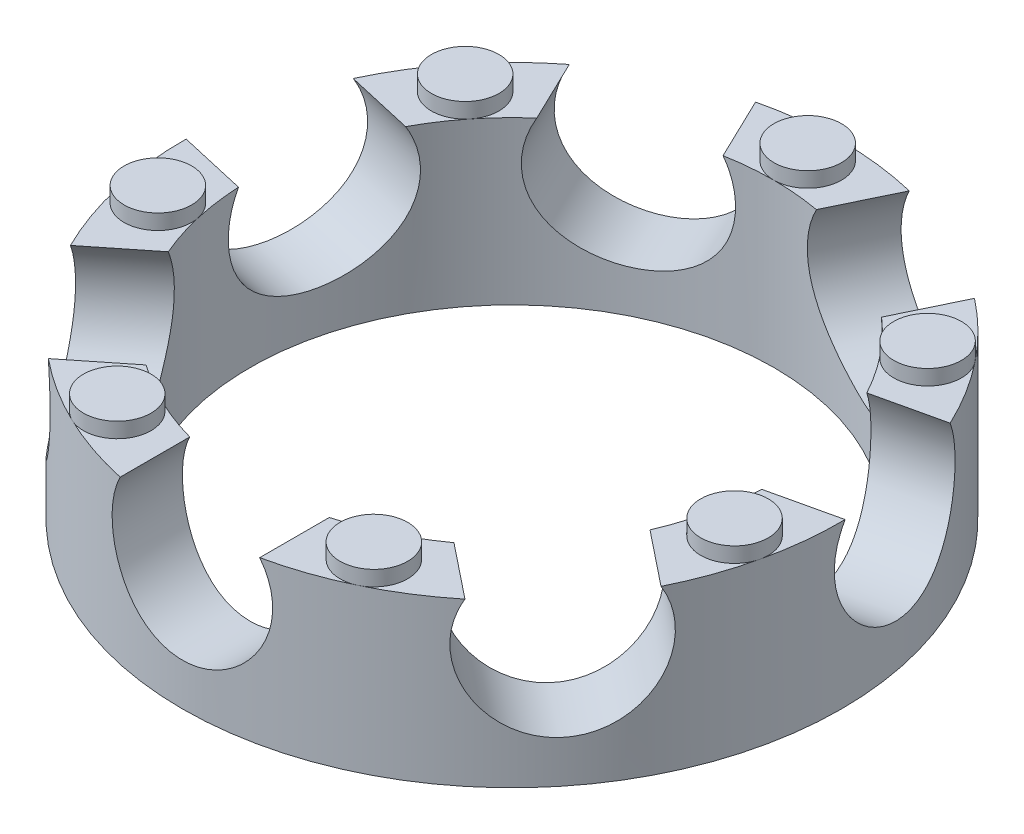
from build123d import *

# Parameters (mm, degrees)
SKETCH1_R           = 4.953
BOSS_EXTRUDE1_DEPTH = 2.4384
SKETCH2_R           = 3.937
CUT_EXTRUDE1_DEPTH  = 2.4384
SKETCH3_R           = 0.508
BOSS_EXTRUDE2_DEPTH = 2.667
CUT_EXTRUDE2_START  = 3.747576
SKETCH4_R           = 1.2065
CUT_EXTRUDE2_DEPTH  = 1.205424
CIRPATTERN1_COUNT   = 7


with BuildPart() as part:
    # Sketch1 → Boss-Extrude1 (new body)
    with BuildSketch(Plane(origin=(0, 0, 0), x_dir=(1, 0, 0), z_dir=(0, 1, 0))):
        Circle(SKETCH1_R)
    extrude(amount=BOSS_EXTRUDE1_DEPTH)

    # Sketch2 → Cut-Extrude1 (cut)
    with BuildSketch(Plane(origin=(0, 2.4384, 0), x_dir=(1, 0, 0), z_dir=(0, 1, 0))):
        Circle(SKETCH2_R)
    extrude(amount=-CUT_EXTRUDE1_DEPTH, mode=Mode.SUBTRACT)

    # Sketch3 → Boss-Extrude2 (add)
    with BuildSketch(Plane(origin=(0, 0, 0), x_dir=(1, 0, 0), z_dir=(0, 1, 0))):
        with Locations((0, 4.445)):
            Circle(SKETCH3_R)
        with Locations((3.47524094, 2.771412169)):
            Circle(SKETCH3_R)
        with Locations((4.33355457, -0.989105551)):
            Circle(SKETCH3_R)
        with Locations((1.92861322, -4.004806618)):
            Circle(SKETCH3_R)
        with Locations((-1.92861322, -4.004806618)):
            Circle(SKETCH3_R)
        with Locations((-4.33355457, -0.989105551)):
            Circle(SKETCH3_R)
        with Locations((-3.47524094, 2.771412169)):
            Circle(SKETCH3_R)
    extrude(amount=BOSS_EXTRUDE2_DEPTH)

    # Sketch4 → Cut-Extrude2 (cut)
    with BuildSketch(Plane.XY.offset(CUT_EXTRUDE2_START)):
        with Locations((0, 1.8415)):
            Circle(SKETCH4_R)
    cut_extrude2 = extrude(amount=CUT_EXTRUDE2_DEPTH, mode=Mode.SUBTRACT)

    # CirPattern1: Cut-Extrude2 ×7 about axis
    cirpattern1_axis = Axis((0, 0, 0), (0, -1, 0))
    for i in range(1, CIRPATTERN1_COUNT):
        add(cut_extrude2.rotate(cirpattern1_axis, i * 360 / CIRPATTERN1_COUNT), mode=Mode.SUBTRACT)


solid = part.part
